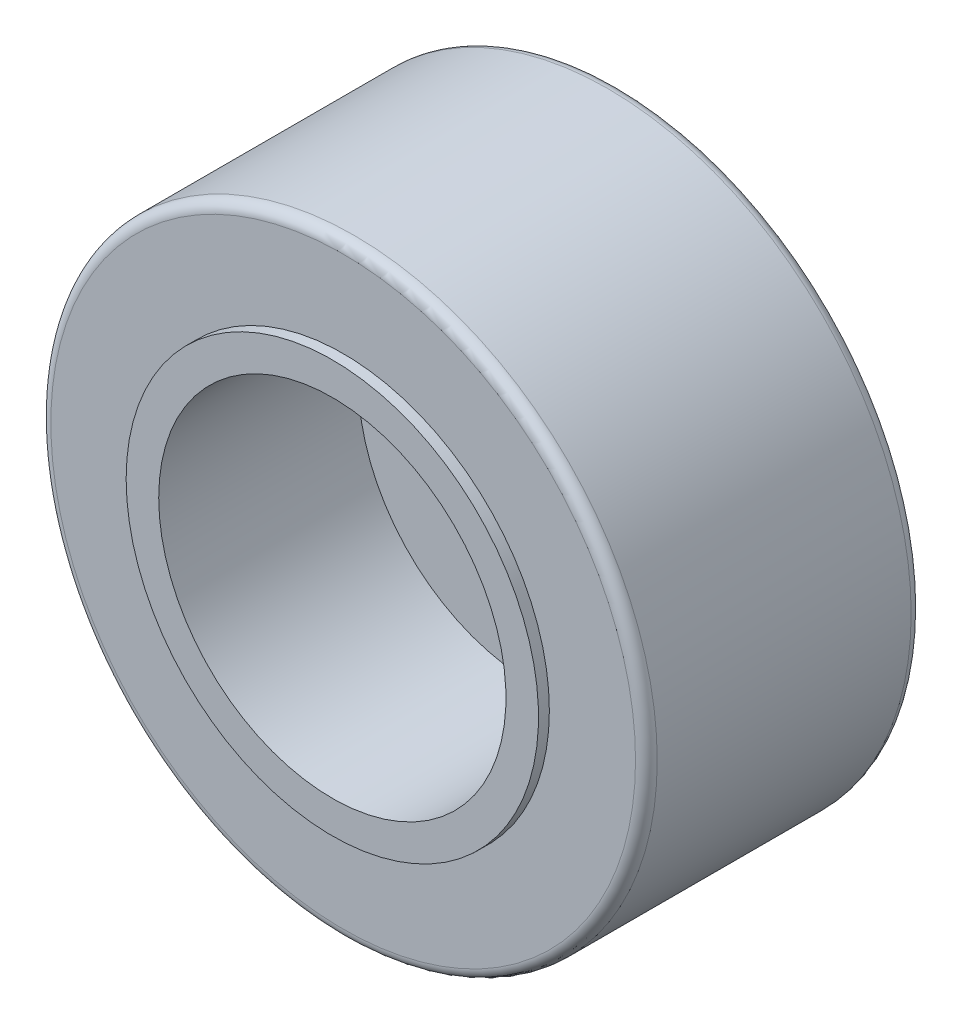
from build123d import *

# Parameters (mm, degrees)
SKETCH1_R           = 13.97
SKETCH1_R_2         = 8.5
BOSS_EXTRUDE1_DEPTH = 12.7
FILLET1_R           = 0.5


with BuildPart() as part:
    # Sketch1 → Boss-Extrude1 (new body)
    with BuildSketch(Plane.XY):
        Circle(SKETCH1_R)
        Circle(SKETCH1_R_2, mode=Mode.SUBTRACT)
    extrude(amount=BOSS_EXTRUDE1_DEPTH)

    # Fillet1
    fillet1_edges = [part.edges().sort_by_distance(p)[0] for p in [
        (-13.97, 0, 0),
        (-13.97, 0, 12.7),
    ]]
    fillet(fillet1_edges, radius=FILLET1_R)

    # Sketch2 → Revolve1 (revolve)
    with BuildSketch(Plane(origin=(0, 0, 0), x_dir=(0, 0, -1), z_dir=(1, 0, 0))):
        Polygon((0, 8.5), (-12.7, 8.5), (-12.7, 9.5), (-13.2, 9.5), (-13.2, 8), (-4, 8), (-4, 1.5), (0.5, 1.5), (0.5, 9.5), (0, 9.5), align=None)
    revolve(axis=Axis((0, 0, 0), (0, 0, 1)))


solid = part.part
